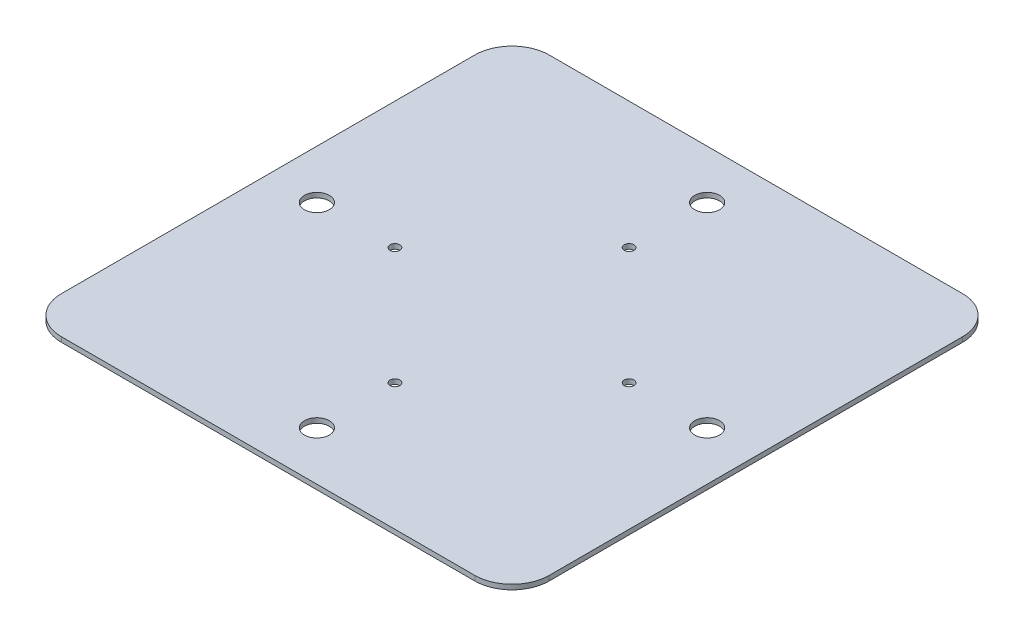
from build123d import *

# Parameters (mm, degrees)
BOSS_EXTRUDE1_DEPTH = 1
SKETCH2_R           = 2.55
CUT_EXTRUDE6_DEPTH  = 2.54
SKETCH3_R           = 1
CUT_EXTRUDE7_DEPTH  = 2.54


with BuildPart() as part:
    # Sketch1 → Boss-Extrude1 (new body)
    with BuildSketch(Plane(origin=(0, 0, 0), x_dir=(1, 0, 0), z_dir=(0, 1, 0))):
        with BuildLine():
            Line((-42.38, -50), (42.38, -50))
            ThreePointArc((42.38, -50), (47.768153673, -47.768153673), (50, -42.38))
            Line((50, -42.38), (50, 42.38))
            ThreePointArc((50, 42.38), (47.768153673, 47.768153673), (42.38, 50))
            Line((42.38, 50), (-42.38, 50))
            ThreePointArc((-42.38, 50), (-47.768153673, 47.768153673), (-50, 42.38))
            Line((-50, 42.38), (-50, -42.38))
            ThreePointArc((-50, -42.38), (-47.768153673, -47.768153673), (-42.38, -50))
        make_face()
    extrude(amount=BOSS_EXTRUDE1_DEPTH)

    # Sketch2 → Cut-Extrude6 (cut)
    with BuildSketch(Plane(origin=(0, 1, 0), x_dir=(1, 0, 0), z_dir=(0, 1, 0))):
        with Locations((0, 40)):
            Circle(SKETCH2_R)
        with Locations((40, 0)):
            Circle(SKETCH2_R)
        with Locations((0, -40)):
            Circle(SKETCH2_R)
        with Locations((-40, 0)):
            Circle(SKETCH2_R)
    extrude(amount=-CUT_EXTRUDE6_DEPTH, mode=Mode.SUBTRACT)

    # Sketch3 → Cut-Extrude7 (cut)
    with BuildSketch(Plane(origin=(0, 1, 0), x_dir=(1, 0, 0), z_dir=(0, 1, 0))):
        with Locations((0, 24)):
            Circle(SKETCH3_R)
        with Locations((24, 0)):
            Circle(SKETCH3_R)
        with Locations((0, -24)):
            Circle(SKETCH3_R)
        with Locations((-24, 0)):
            Circle(SKETCH3_R)
    extrude(amount=-CUT_EXTRUDE7_DEPTH, mode=Mode.SUBTRACT)


solid = part.part
